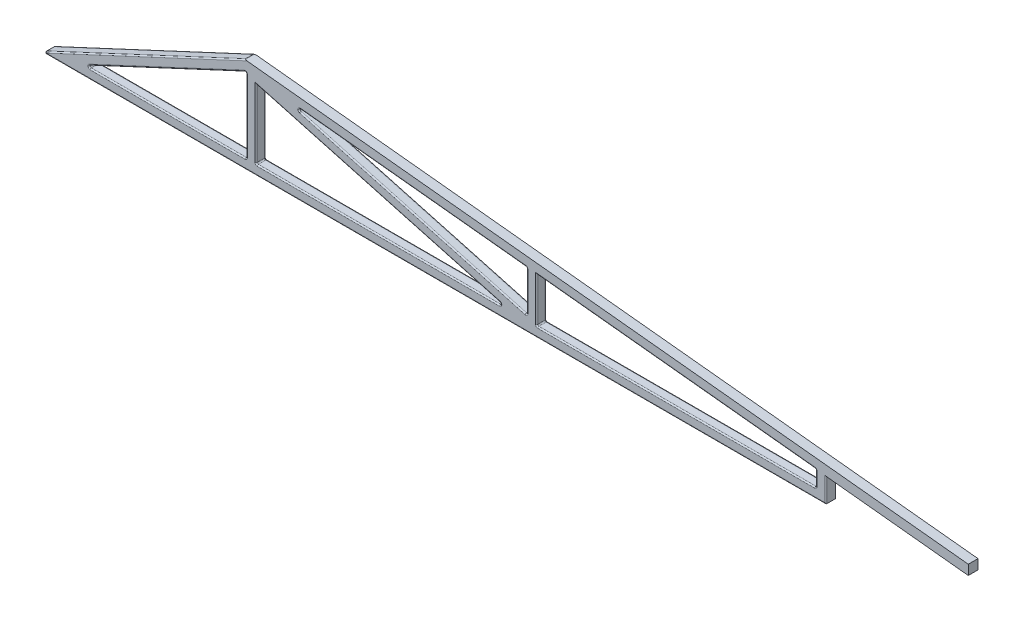
from build123d import *

# Parameters (mm, degrees)
BOSS_EXTRUDE1_DEPTH = 40
FILLET1_R           = 5


with BuildPart() as part:
    # Sketch1 → Boss-Extrude1 (new body)
    with BuildSketch(Plane.XY):
        Polygon((3230, 101.244659806), (3230, 40), (3230, 0), (0, 0), (838.334703009, 390.92189211), (3817.174656528, 80.216997848), (3817.174656528, 40), align=None)
        Polygon((1999.865756907, 229.552570232), (1999.865756907, 40), (885.201227588, 40), (885.201227588, 345.816528727), align=None, mode=Mode.SUBTRACT)
        Polygon((2039.865756907, 225.380410611), (2039.865756907, 40), (3190, 40), (3190, 105.416819427), align=None, mode=Mode.SUBTRACT)
        Polygon((845.201227588, 349.988688348), (845.201227588, 40), (180.428340146, 40), align=None, mode=Mode.SUBTRACT)
        Polygon((1007.157367821, 333.096016633), (885.201227588, 345.816528727), (885.201227588, 325.077463987), (1924.274355967, 40), (1999.865756907, 40), (1999.865756907, 60.73906474), align=None)
    extrude(amount=BOSS_EXTRUDE1_DEPTH)

    # Fillet1
    fillet1_edges = [part.edges().sort_by_distance(p)[0] for p in [
        (1404.737791778, 182.538731994, 0),
        (885.201227588, 182.538731994, 0),
        (1503.511562364, 281.324293432, 0),
        (2614.932878453, 165.398615019, 0),
        (2039.865756907, 132.690205306, 0),
        (512.814783867, 194.994344174, 0),
        (1404.737791778, 40, 0),
        (1999.865756907, 145.145817486, 0),
        (1503.511562364, 196.917540686, 0),
        (3190, 72.708409713, 0),
        (2614.932878453, 40, 0),
        (845.201227588, 194.994344174, 0),
        (512.814783867, 40, 0),
        (419.167351504, 195.460946055, 0),
        (1404.737791778, 182.538731994, 40),
        (1404.737791778, 40, 40),
        (885.201227588, 182.538731994, 40),
        (1999.865756907, 145.145817486, 40),
        (1503.511562364, 196.917540686, 40),
        (1503.511562364, 281.324293432, 40),
        (2039.865756907, 132.690205306, 40),
        (2614.932878453, 165.398615019, 40),
        (3190, 72.708409713, 40),
        (2614.932878453, 40, 40),
        (845.201227588, 194.994344174, 40),
        (512.814783867, 40, 40),
        (512.814783867, 194.994344174, 40),
        (3230, 50.622329903, 40),
        (419.167351504, 195.460946055, 40),
        (1615, 0, 40),
        (885.201227588, 40, 20),
        (1924.274355967, 40, 20),
        (1999.865756907, 229.552570232, 20),
        (1007.157367821, 333.096016633, 20),
        (1999.865756907, 60.73906474, 20),
        (2039.865756907, 40, 20),
        (3190, 40, 20),
        (3190, 105.416819427, 20),
        (845.201227588, 349.988688348, 20),
        (180.428340146, 40, 20),
        (845.201227588, 40, 20),
        (0, 0, 20),
        (838.334703009, 390.92189211, 20),
    ]]
    fillet(fillet1_edges, radius=FILLET1_R)


solid = part.part
